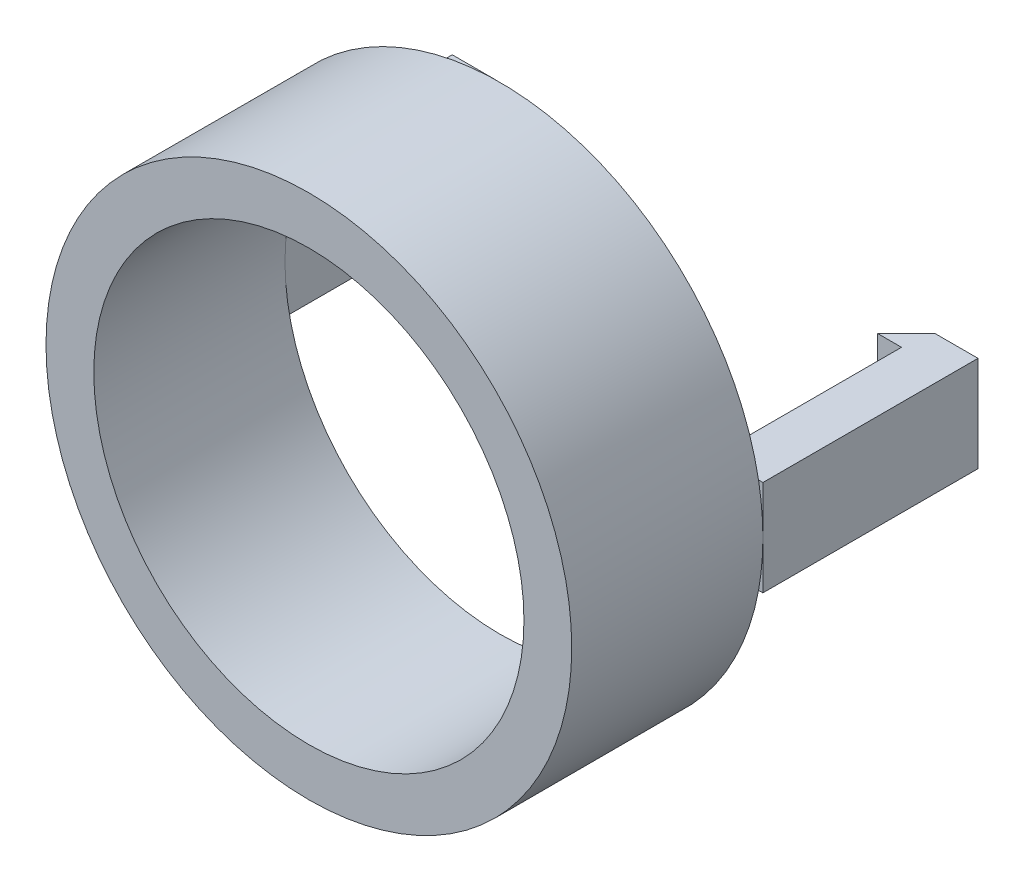
from build123d import *

# Parameters (mm, degrees)
SKETCH1_R           = 11
SKETCH1_R_2         = 9
BOSS_EXTRUDE1_DEPTH = 8
BOSS_EXTRUDE2_DEPTH = 2


with BuildPart() as part:
    # Sketch1 → Boss-Extrude1 (new body)
    with BuildSketch(Plane.XY):
        Circle(SKETCH1_R)
        Circle(SKETCH1_R_2, mode=Mode.SUBTRACT)
    extrude(amount=BOSS_EXTRUDE1_DEPTH)

    # Sketch2 → Boss-Extrude2 (add, symmetric)
    with BuildSketch(Plane(origin=(0, 0, 0), x_dir=(1, 0, 0), z_dir=(0, 1, 0))):
        Polygon((-11, 0), (-11, 9), (-9.2, 9), (-8, 7.8), (-9, 7.8), (-9, 0), align=None)
        Polygon((9, 0), (11, 0), (11, 9), (9.2, 9), (8, 7.8), (9, 7.8), align=None)
    extrude(amount=BOSS_EXTRUDE2_DEPTH, both=True)


solid = part.part
